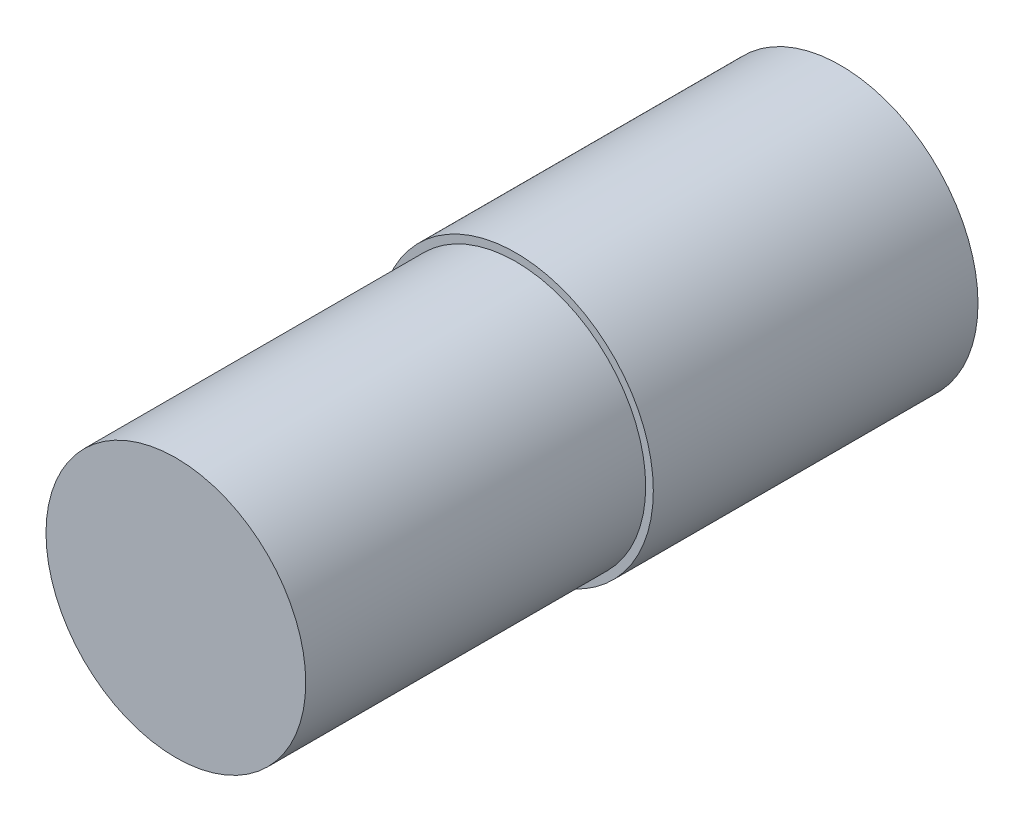
from build123d import *

# Parameters (mm, degrees)
SKETCH1_R      = 18
GEARBOX_DEPTH  = 42.5
SKETCH2_R      = 17
MOTOR_DEPTH    = 44.5
SKETCH3_R      = 11
PLATFORM_DEPTH = 2
SKETCH4_R      = 1.5
SCREWS_DEPTH   = 5


with BuildPart() as part:
    # Sketch1 → Gearbox (new body)
    with BuildSketch(Plane.XY):
        Circle(SKETCH1_R)
    extrude(amount=GEARBOX_DEPTH)

    # Sketch2 → Motor (add)
    with BuildSketch(Plane.XY.offset(42.5)):
        Circle(SKETCH2_R)
    extrude(amount=MOTOR_DEPTH)

    # Sketch3 → Platform (add)
    with BuildSketch(Plane(origin=(0, 0, 0), x_dir=(-1, 0, 0), z_dir=(0, 0, -1))):
        Circle(SKETCH3_R)
    extrude(amount=PLATFORM_DEPTH)

    # Sketch4 → Screws (cut)
    with BuildSketch(Plane(origin=(0, 0, 0), x_dir=(-1, 0, 0), z_dir=(0, 0, -1))):
        with Locations((0, 14)):
            Circle(SKETCH4_R)
        with Locations((14, 0)):
            Circle(SKETCH4_R)
        with Locations((0, -14)):
            Circle(SKETCH4_R)
        with Locations((-14, 0)):
            Circle(SKETCH4_R)
    extrude(amount=-SCREWS_DEPTH, mode=Mode.SUBTRACT)


solid = part.part
